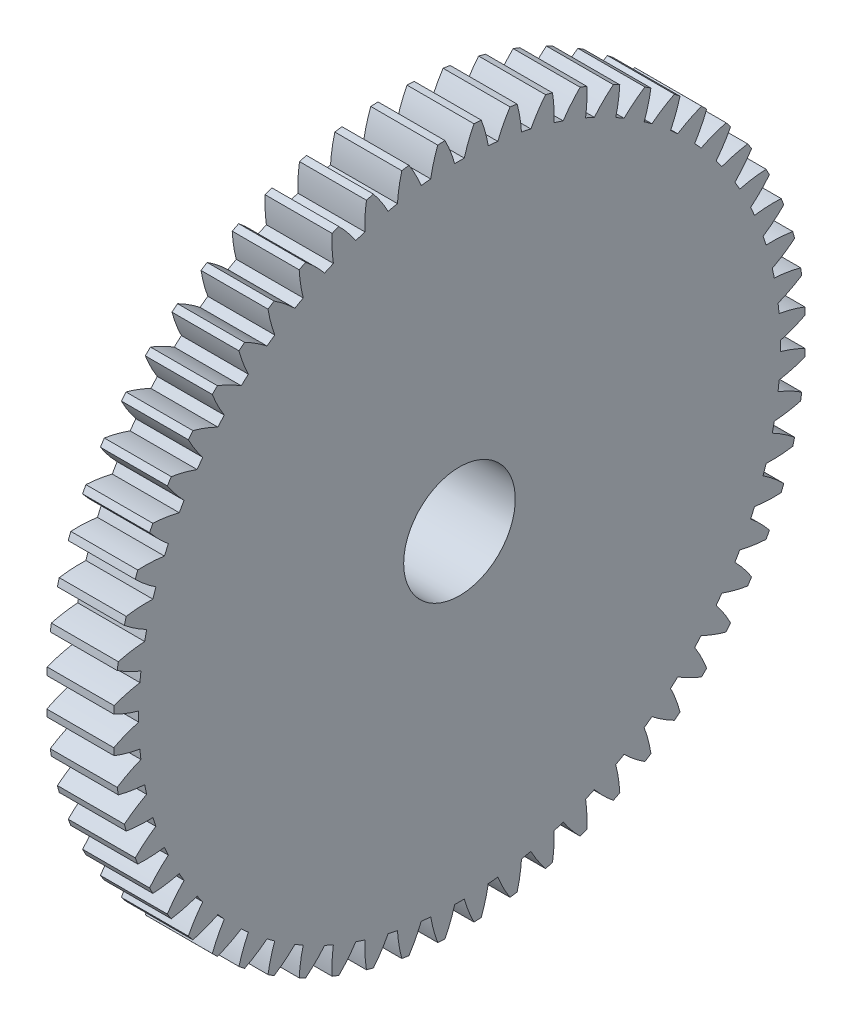
from build123d import *

# Parameters (mm, degrees)
BASPROSKE_W      = 3
BASPROSKE_H      = 15.5
TOOTHCUT_DEPTH   = 23.12464689
TEETHCUTS_COUNT  = 60
TEETHCUTS_ANGLE  = 354
HUBNEAONESKE_R   = 4.5
HUBNEARONE_DEPTH = 5.0000508
BORSKE_R         = 2.5
BORE_DEPTH       = 8.0000508


with BuildPart() as part:
    # BasProSke → Base-Revolve (revolve)
    with BuildSketch(Plane(origin=(0, 0, 0), x_dir=(1, 0, 0), z_dir=(0, 1, 0)), mode=Mode.PRIVATE) as base_revolve_sk:
        with Locations((1.5, 7.75)):
            Rectangle(BASPROSKE_W, BASPROSKE_H)
    revolve(base_revolve_sk.sketch.rotate(Axis((-10, 0, 0), (1, 0, 0)), 180), axis=Axis((-10, 0, 0), (1, 0, 0)))

    # TooCutSke → ToothCut (cut, through all)
    with BuildSketch(Plane(origin=(0, 0, 0), x_dir=(0, 0, -1), z_dir=(1, 0, 0))):
        with BuildLine():
            ThreePointArc((0.21493681, 14.372392917), (0, 14.374), (-0.21493681, 14.372392917))
            ThreePointArc((-0.21493681, 14.372392917), (-0.409732631, 14.953266942), (-0.662749221, 15.51124781))
            ThreePointArc((-0.662749221, 15.51124781), (0, 15.5254), (0.662749221, 15.51124781))
            ThreePointArc((0.662749221, 15.51124781), (0.409732631, 14.953266942), (0.21493681, 14.372392917))
        make_face()
    toothcut = extrude(amount=TOOTHCUT_DEPTH, mode=Mode.SUBTRACT)

    # TeethCuts: ToothCut ×60 about axis
    teethcuts_axis = Axis((-10, 0, 0), (1, 0, 0))
    for i in range(1, TEETHCUTS_COUNT):
        add(toothcut.rotate(teethcuts_axis, i * TEETHCUTS_ANGLE / (TEETHCUTS_COUNT - 1)), mode=Mode.SUBTRACT)

    # HubNeaOneSke → HubNearOne (add)
    with BuildSketch(Plane.ZY):
        with Locations(Location((0, 0, 0), (0, 0, 180))):
            Circle(HUBNEAONESKE_R)
    extrude(amount=HUBNEARONE_DEPTH)

    # BorSke → Bore (cut, symmetric)
    with BuildSketch(Plane(origin=(0, 0, 0), x_dir=(0, 0, -1), z_dir=(1, 0, 0))):
        with Locations(Location((0, 0, 0), (0, 0, 180))):
            Circle(BORSKE_R)
    extrude(amount=BORE_DEPTH, both=True, mode=Mode.SUBTRACT)


solid = part.part
